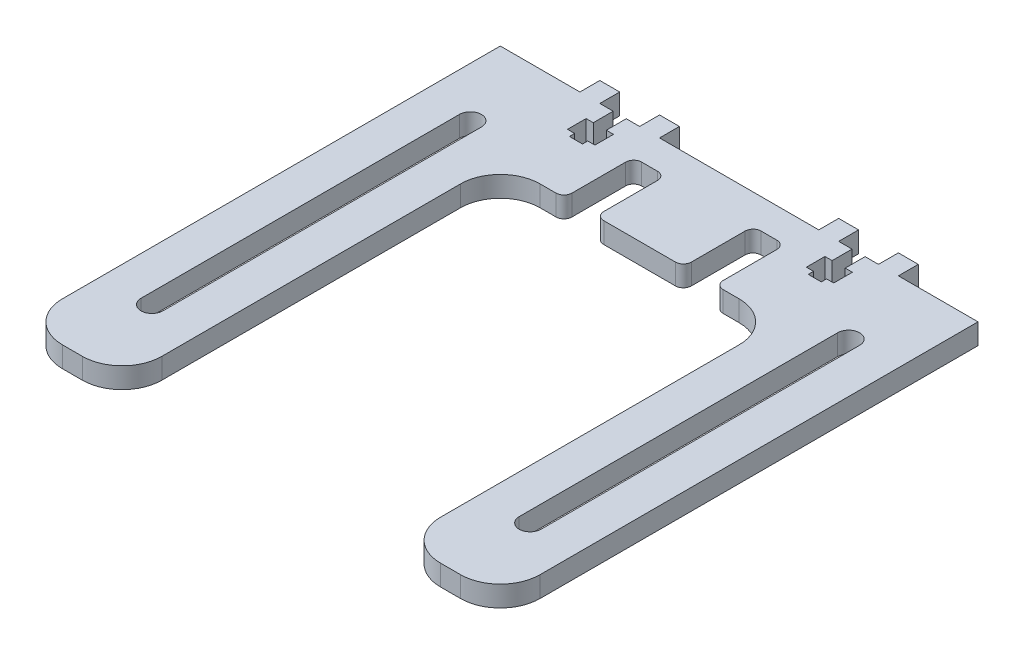
from build123d import *

# Parameters (mm, degrees)
BOSS_EXTRUDE1_DEPTH = 6.604
CUT_EXTRUDE1_DEPTH  = 7.604
FILLET1_R           = 12.7
CUT_EXTRUDE2_DEPTH  = 7.604
SKETCH5_W           = 6.35
SKETCH5_H           = 6.35
BOSS_EXTRUDE2_DEPTH = 6.604
SKETCH6_W           = 10.16
SKETCH6_H           = 22.225
CUT_EXTRUDE5_DEPTH  = 7.604
FILLET2_R           = 2.54


with BuildPart() as part:
    # Sketch1 → Boss-Extrude1 (new body)
    with BuildSketch(Plane(origin=(0, 0, 0), x_dir=(1, 0, 0), z_dir=(0, 1, 0))):
        Polygon((44.45, -152.4), (76.2, -152.4), (76.2, 0), (-76.2, 0), (-76.2, -152.4), (-44.45, -152.4), (-44.45, -31.75), (44.45, -31.75), align=None)
    extrude(amount=BOSS_EXTRUDE1_DEPTH)

    # Sketch2 → Cut-Extrude1 (cut, through all)
    with BuildSketch(Plane(origin=(0, 6.604, 0), x_dir=(1, 0, 0), z_dir=(0, 1, 0))):
        with BuildLine():
            Line((-56.8325, -25.4), (-56.8325, -127))
            ThreePointArc((-56.8325, -127), (-60.325, -130.4925), (-63.8175, -127))
            Line((-63.8175, -127), (-63.8175, -25.4))
            ThreePointArc((-63.8175, -25.4), (-60.325, -21.9075), (-56.8325, -25.4))
        make_face()
        with BuildLine():
            Line((56.8325, -25.4), (56.8325, -127))
            ThreePointArc((56.8325, -127), (60.325, -130.4925), (63.8175, -127))
            Line((63.8175, -127), (63.8175, -25.4))
            ThreePointArc((63.8175, -25.4), (60.325, -21.9075), (56.8325, -25.4))
        make_face()
    extrude(amount=-CUT_EXTRUDE1_DEPTH, mode=Mode.SUBTRACT)

    # Fillet1
    fillet1_edges = [part.edges().sort_by_distance(p)[0] for p in [
        (76.2, 3.302, 152.4),
        (44.45, 3.302, 152.4),
        (44.45, 3.302, 31.75),
        (-44.45, 3.302, 31.75),
        (-44.45, 3.302, 152.4),
        (-76.2, 3.302, 152.4),
    ]]
    fillet(fillet1_edges, radius=FILLET1_R)

    # Sketch4 → Cut-Extrude2 (cut, through all)
    with BuildSketch(Plane(origin=(0, 6.604, 0), x_dir=(1, 0, 0), z_dir=(0, 1, 0))):
        Polygon((-40.1828, 0), (-40.1828, -6.35), (-42.4688, -6.35), (-42.4688, -12.2936), (-40.1828, -12.2936), (-40.1828, -13.97), (-36.0172, -13.97), (-36.0172, -12.2936), (-33.7312, -12.2936), (-33.7312, -6.35), (-36.0172, -6.35), (-36.0172, 0), align=None)
        Polygon((36.0172, 0), (36.0172, -6.35), (33.7312, -6.35), (33.7312, -12.2936), (36.0172, -12.2936), (36.0172, -13.97), (40.1828, -13.97), (40.1828, -12.2936), (42.4688, -12.2936), (42.4688, -6.35), (40.1828, -6.35), (40.1828, 0), align=None)
    extrude(amount=-CUT_EXTRUDE2_DEPTH, mode=Mode.SUBTRACT)

    # Sketch5 → Boss-Extrude2 (add)
    with BuildSketch(Plane(origin=(0, 6.604, 0), x_dir=(1, 0, 0), z_dir=(0, 1, 0))):
        with Locations((-47.625, 3.175)):
            Rectangle(SKETCH5_W, SKETCH5_H)
        with Locations((-28.575, 3.175)):
            Rectangle(SKETCH5_W, SKETCH5_H)
        with Locations((47.625, 3.175)):
            Rectangle(SKETCH5_W, SKETCH5_H)
        with Locations((28.575, 3.175)):
            Rectangle(SKETCH5_W, SKETCH5_H)
    extrude(amount=-BOSS_EXTRUDE2_DEPTH)

    # Sketch6 → Cut-Extrude5 (cut, through all)
    with BuildSketch(Plane(origin=(0, 6.604, 0), x_dir=(1, 0, 0), z_dir=(0, 1, 0))):
        with Locations((-19.05, -20.6375)):
            Rectangle(SKETCH6_W, SKETCH6_H)
        with Locations((19.05, -20.6375)):
            Rectangle(SKETCH6_W, SKETCH6_H)
    extrude(amount=-CUT_EXTRUDE5_DEPTH, mode=Mode.SUBTRACT)

    # Fillet2
    fillet2_edges = [part.edges().sort_by_distance(p)[0] for p in [
        (-24.13, 3.302, 31.75),
        (-24.13, 3.302, 9.525),
        (-13.97, 3.302, 9.525),
        (-13.97, 3.302, 31.75),
        (13.97, 3.302, 31.75),
        (13.97, 3.302, 9.525),
        (24.13, 3.302, 9.525),
        (24.13, 3.302, 31.75),
    ]]
    fillet(fillet2_edges, radius=FILLET2_R)


solid = part.part
